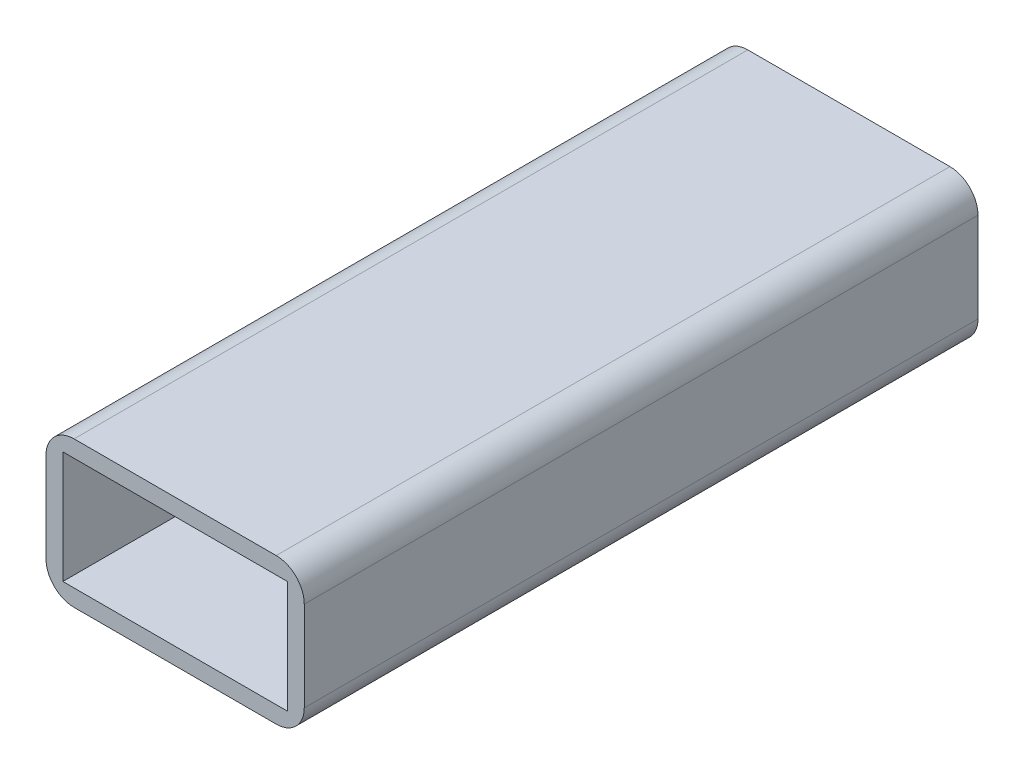
from build123d import *

# Parameters (mm, degrees)
SKETCH1_W           = 46
SKETCH1_H           = 26
SKETCH1_W_2         = 40
SKETCH1_H_2         = 20
EXTRUDE_THIN1_DEPTH = 120
FILLET2_R           = 5


with BuildPart() as part:
    # Sketch1 → Extrude-Thin1 (new body)
    with BuildSketch(Plane.XY):
        Rectangle(SKETCH1_W, SKETCH1_H)
        Rectangle(SKETCH1_W_2, SKETCH1_H_2, mode=Mode.SUBTRACT)
    extrude(amount=EXTRUDE_THIN1_DEPTH)

    # Fillet2
    fillet2_edges = [part.edges().sort_by_distance(p)[0] for p in [
        (-23, 13, 60),
        (23, 13, 60),
        (23, -13, 60),
        (-23, -13, 60),
    ]]
    fillet(fillet2_edges, radius=FILLET2_R)


solid = part.part
